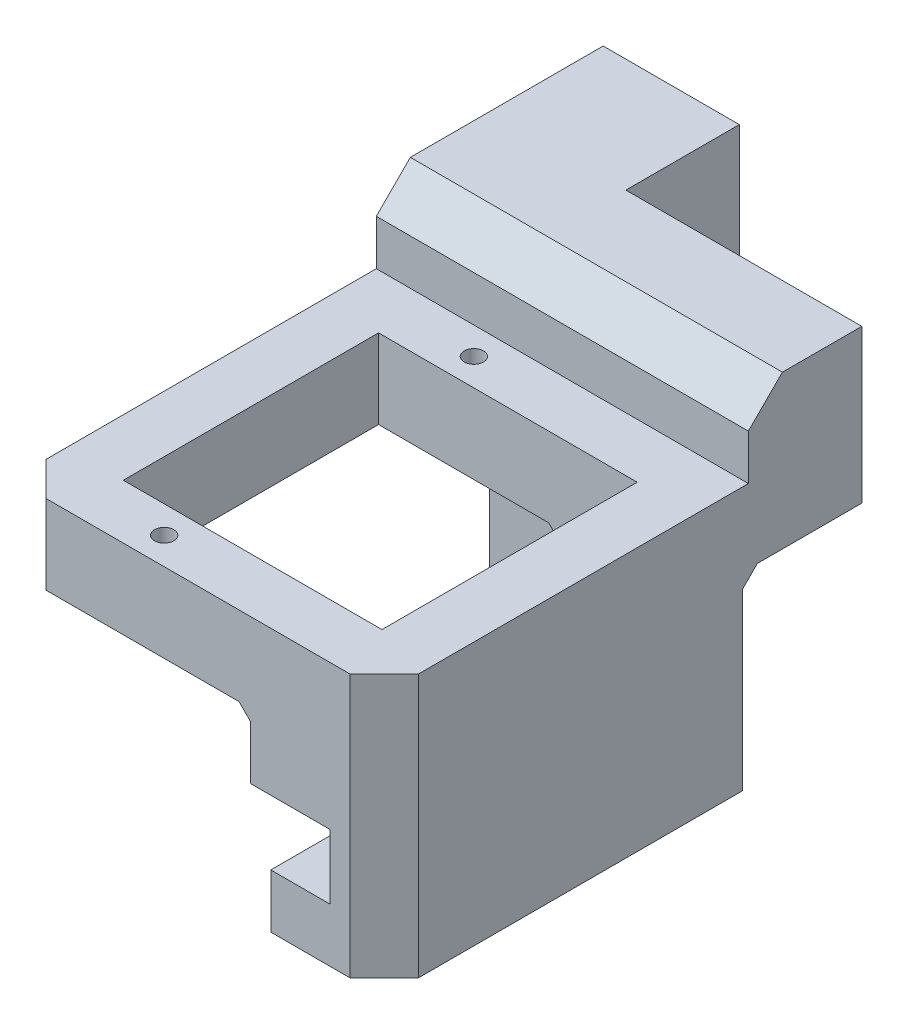
from build123d import *

# Parameters (mm, degrees)
SKETCH1_R                = 0.85
BOSS_EXTRUDE1_DEPTH      = 7
BOSS_EXTRUDE2_DEPTH      = 11.2
BOSS_EXTRUDE2_DEPTH_BACK = 7
SKETCH3_W                = 11
SKETCH3_H                = 11.2
CUT_EXTRUDE1_DEPTH       = 42
SKETCH4_W                = 10
SKETCH4_H                = 32.1
BOSS_EXTRUDE3_DEPTH      = 5
SKETCH5_W                = 7
SKETCH5_H                = 6
BOSS_EXTRUDE4_DEPTH      = 32.1
SKETCH6_W                = 32.8
SKETCH6_H                = 7
BOSS_EXTRUDE5_DEPTH      = 10
SKETCH8_W                = 10
SKETCH8_H                = 7
BOSS_EXTRUDE7_DEPTH      = 32.8
CHAMFER2_SIZE            = 1
CHAMFER3_SIZE            = 3
CHAMFER4_SIZE            = 3
CHAMFER8_SIZE            = 0.5
CHAMFER9_SIZE            = 1
SKETCH13_W               = 12
SKETCH13_H               = 45.14
BOSS_EXTRUDE10_DEPTH     = 10
SKETCH14_R               = 2.05
CUT_EXTRUDE2_DEPTH       = 5
SKETCH15_W               = 7
SKETCH15_H               = 0.25
CUT_EXTRUDE3_DEPTH       = 39


with BuildPart() as part:
    # Sketch1 → Boss-Extrude1 (new body)
    with BuildSketch(Plane(origin=(0, 0, 0), x_dir=(1, 0, 0), z_dir=(0, 1, 0))):
        Polygon((0, -16.05), (0, 16.05), (17, 16.05), (17, 11.25), (5, 11.25), (5, -11.25), (17, -11.25), (17, -16.05), align=None)
        with Locations((11, 13.65)):
            Circle(SKETCH1_R, mode=Mode.SUBTRACT)
        with Locations((11, -13.65)):
            Circle(SKETCH1_R, mode=Mode.SUBTRACT)
    extrude(amount=BOSS_EXTRUDE1_DEPTH)

    # Sketch2 → Boss-Extrude2 (add, two sides)
    with BuildSketch(Plane.XZ) as boss_extrude2_sk:
        Polygon((17, 11.25), (27.8, 11.25), (27.8, -11.25), (17, -11.25), (17, -16.05), (32.8, -16.05), (32.8, 16.05), (17, 16.05), align=None)
    extrude(amount=BOSS_EXTRUDE2_DEPTH)
    extrude(boss_extrude2_sk.sketch, amount=-BOSS_EXTRUDE2_DEPTH_BACK)

    # Sketch3 → Cut-Extrude1 (cut)
    with BuildSketch(Plane.XY.offset(16.05)):
        with Locations((22.5, -5.6)):
            Rectangle(SKETCH3_W, SKETCH3_H)
    extrude(amount=-CUT_EXTRUDE1_DEPTH, mode=Mode.SUBTRACT)

    # Sketch4 → Boss-Extrude3 (add)
    with BuildSketch(Plane.XZ.offset(11.2)):
        with Locations((27.8, 0)):
            Rectangle(SKETCH4_W, SKETCH4_H)
    extrude(amount=BOSS_EXTRUDE3_DEPTH)

    # Sketch5 → Boss-Extrude4 (add)
    with BuildSketch(Plane.XY.offset(16.05)):
        with Locations((24.5, -3)):
            Rectangle(SKETCH5_W, SKETCH5_H)
    extrude(amount=-BOSS_EXTRUDE4_DEPTH)



with BuildPart() as body_2:
    # Sketch6 → Boss-Extrude5 (new body)
    with BuildSketch(Plane(origin=(0, 0, -16.05), x_dir=(-1, 0, 0), z_dir=(0, 0, -1))):
        with Locations((-16.4, 10.5)):
            Rectangle(SKETCH6_W, SKETCH6_H)
    extrude(amount=BOSS_EXTRUDE5_DEPTH)


with BuildPart() as part_1:
    add(part.part)

    add(body_2.part)  # Boss-Extrude7 merges body 2
    # Sketch8 → Boss-Extrude7 (add)
    with BuildSketch(Plane.ZY):
        with Locations((-21.05, 3.5)):
            Rectangle(SKETCH8_W, SKETCH8_H)
    extrude(amount=-BOSS_EXTRUDE7_DEPTH)

    # Chamfer2
    chamfer2_edges = [part_1.edges().sort_by_distance(p)[0] for p in [
        (26.9, 0, -16.05),
    ]]
    chamfer(chamfer2_edges, length=CHAMFER2_SIZE)

    # Chamfer3
    chamfer3_edges = [part_1.edges().sort_by_distance(p)[0] for p in [
        (0, 3.5, 16.05),
        (32.8, -4.6, 16.05),
    ]]
    chamfer(chamfer3_edges, length=CHAMFER3_SIZE)

    # Chamfer4
    chamfer4_edges = [part_1.edges().sort_by_distance(p)[0] for p in [
        (16.4, 14, -16.05),
    ]]
    chamfer(chamfer4_edges, length=CHAMFER4_SIZE)

    # Chamfer8
    chamfer8_edges = [part_1.edges().sort_by_distance(p)[0] for p in [
        (32.8, 0, -21.55),
        (32.8, -8.6, -16.05),
        (32.8, -0.5, -16.55),
        (27.8, -16.2, -16.05),
    ]]
    chamfer(chamfer8_edges, length=CHAMFER8_SIZE)

    # Chamfer9
    chamfer9_edges = [part_1.edges().sort_by_distance(p)[0] for p in [
        (21, 0, -13.65),
        (21, 0, 13.65),
    ]]
    chamfer(chamfer9_edges, length=CHAMFER9_SIZE)

    # Sketch13 → Boss-Extrude10 (add)
    with BuildSketch(Plane(origin=(0, 0, -26.05), x_dir=(-1, 0, 0), z_dir=(0, 0, -1))):
        with Locations((-6, -8.57)):
            Rectangle(SKETCH13_W, SKETCH13_H)
    extrude(amount=BOSS_EXTRUDE10_DEPTH)

    # Sketch14 → Cut-Extrude2 (cut)
    with BuildSketch(Plane(origin=(0, 0, -36.05), x_dir=(-1, 0, 0), z_dir=(0, 0, -1))):
        with Locations((-6, 1.43)):
            Circle(SKETCH14_R)
        with Locations((-6, -18.57)):
            Circle(SKETCH14_R)
    extrude(amount=-CUT_EXTRUDE2_DEPTH, mode=Mode.SUBTRACT)

    # Sketch15 → Cut-Extrude3 (cut)
    with BuildSketch(Plane.XY.offset(16.05)):
        with Locations((24.5, -11.325)):
            Rectangle(SKETCH15_W, SKETCH15_H)
        with Locations((24.5, -5.875)):
            Rectangle(SKETCH15_W, SKETCH15_H)
    extrude(amount=-CUT_EXTRUDE3_DEPTH, mode=Mode.SUBTRACT)


solid = part_1.part
